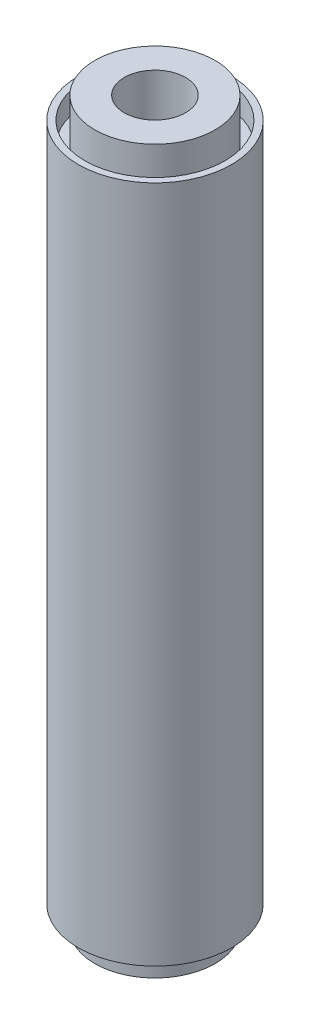
from build123d import *

# Parameters (mm, degrees)
SKETCH1_R           = 44.45
SKETCH1_R_2         = 40.64
BOSS_EXTRUDE1_DEPTH = 393.7
SKETCH3_R           = 40.64
BOSS_EXTRUDE2_DEPTH = 25.4
SKETCH4_R           = 34.925
BOSS_EXTRUDE3_DEPTH = 25.4
SKETCH6_R           = 40.64
BOSS_EXTRUDE4_DEPTH = 25.4
SKETCH7_R           = 34.925
BOSS_EXTRUDE5_DEPTH = 25.4
SKETCH9_R           = 17.78
CUT_EXTRUDE1_DEPTH  = 152.4


with BuildPart() as part:
    # Sketch1 → Boss-Extrude1 (new body)
    with BuildSketch(Plane(origin=(0, 0, 0), x_dir=(1, 0, 0), z_dir=(0, 1, 0))):
        Circle(SKETCH1_R)
        Circle(SKETCH1_R_2, mode=Mode.SUBTRACT)
    extrude(amount=BOSS_EXTRUDE1_DEPTH)

    # Sketch3 → Boss-Extrude2 (add)
    with BuildSketch(Plane(origin=(0, 355.6, 0), x_dir=(1, 0, 0), z_dir=(0, 1, 0))):
        Circle(SKETCH3_R)
    extrude(amount=BOSS_EXTRUDE2_DEPTH)

    # Sketch4 → Boss-Extrude3 (add)
    with BuildSketch(Plane(origin=(0, 381, 0), x_dir=(1, 0, 0), z_dir=(0, 1, 0))):
        Circle(SKETCH4_R)
    extrude(amount=BOSS_EXTRUDE3_DEPTH)

    # Sketch6 → Boss-Extrude4 (add)
    with BuildSketch(Plane(origin=(0, 38.1, 0), x_dir=(-1, 0, 0), z_dir=(0, -1, 0))):
        Circle(SKETCH6_R)
    extrude(amount=BOSS_EXTRUDE4_DEPTH)

    # Sketch7 → Boss-Extrude5 (add)
    with BuildSketch(Plane.XZ.offset(-12.7)):
        Circle(SKETCH7_R)
    extrude(amount=BOSS_EXTRUDE5_DEPTH)

    # Sketch9 → Cut-Extrude1 (cut)
    with BuildSketch(Plane(origin=(0, 406.4, 0), x_dir=(1, 0, 0), z_dir=(0, 1, 0))):
        Circle(SKETCH9_R)
    extrude(amount=-CUT_EXTRUDE1_DEPTH, mode=Mode.SUBTRACT)


solid = part.part
